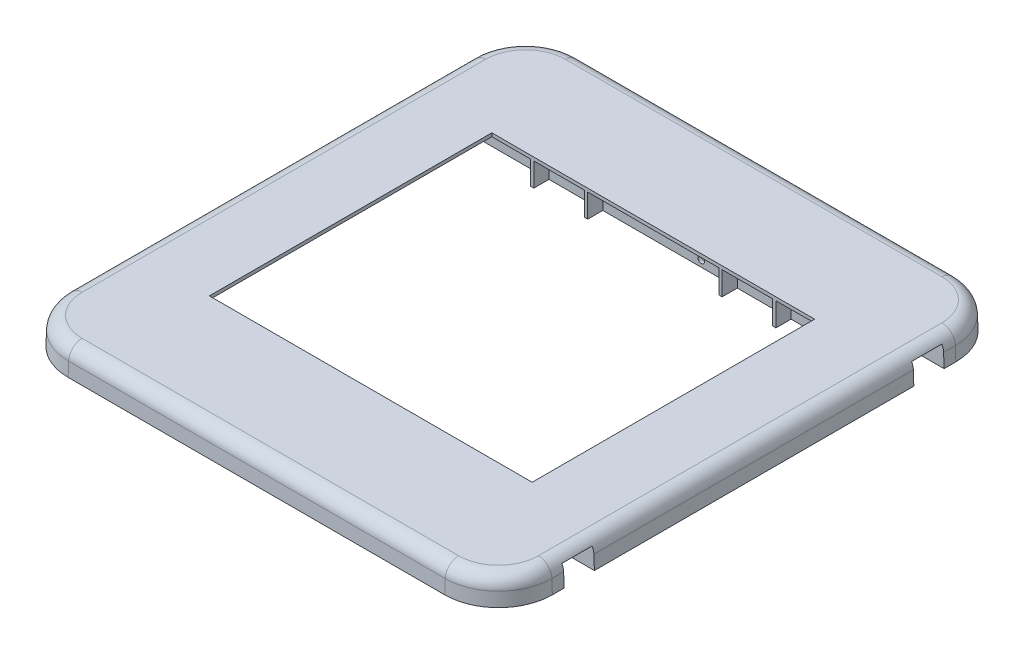
from build123d import *

# Parameters (mm, degrees)
EXTRUDE1_DEPTH     = 25.4
DRAFT1_ANGLE       = -2
FILLET1_R          = 12.7
SHELL2_T           = -3.175
RIB1_REACH         = 335.36
SKETCH3_WALLS_W    = 1109.591591228
SKETCH3_WALLS_H    = 3.175
SKETCH3_WALLS_W_2  = 1112.768526531
SKETCH4_W          = 28.575
SKETCH4_H          = 19.05
CUT_EXTRUDE2_DEPTH = 334.359880758
CUT_EXTRUDE3_REACH = 360.76
CUT_EXTRUDE3_START = -25.4
SKETCH6_R          = 3.175
RIB4_REACH         = 334.936
SKETCH9_WALLS_W    = 3.175
SKETCH9_WALLS_H    = 696.447518122
RIB4_DRAFT_ANGLE   = 2
RIB5_REACH         = 335.36
SKETCH11_WALLS_W   = 3.175
SKETCH11_WALLS_H   = 963.994761516
SKETCH11_WALLS_H_2 = 967.169761516
SKETCH10_W         = 304.8
SKETCH10_H         = 266.7
CUT_EXTRUDE4_DEPTH = 334.359880758


with BuildPart() as part:
    # Sketch1 → Extrude1 (new body)
    with BuildSketch(Plane(origin=(0, 0, 0), x_dir=(1, 0, 0), z_dir=(0, 1, 0))):
        with BuildLine():
            Line((228.6, 0), (228.6, 190.5))
            ThreePointArc((228.6, 190.5), (213.721024484, 226.421024484), (177.8, 241.3))
            Line((177.8, 241.3), (-177.8, 241.3))
            ThreePointArc((-177.8, 241.3), (-213.721024484, 226.421024484), (-228.6, 190.5))
            Line((-228.6, 190.5), (-228.6, 0))
            Line((-228.6, 0), (228.6, 0))
        make_face()
    extrude(amount=EXTRUDE1_DEPTH)

    # Draft1
    draft1_faces = [part.faces().sort_by_distance(p)[0] for p in [
        (228.6, 12.7, -95.25),
    ]]
    draft(draft1_faces, Plane(origin=(-177.8, 0, -190.5), x_dir=(0, 0, -1), z_dir=(0, -1, 0)), DRAFT1_ANGLE)

    # Fillet1
    fillet1_edges = [part.edges().sort_by_distance(p)[0] for p in [
        (227.713012455, 25.4, -95.25),
        (213.093829576, 25.4, -225.793829576),
        (0, 25.4, -240.413012455),
        (-213.093829576, 25.4, -225.793829576),
        (-227.713012455, 25.4, -95.25),
    ]]
    fillet(fillet1_edges, radius=FILLET1_R)

    # Shell2
    shell2_openings = [part.faces().sort_by_distance(p)[0] for p in [
        (0, 12.636517927, 0),
        (0, 0, -119.541485653),
    ]]
    offset(amount=SHELL2_T, openings=shell2_openings, kind=Kind.INTERSECTION)

    # Sketch3 walls → Rib1 (add, up to next)
    with BuildSketch(Plane.XZ, mode=Mode.PRIVATE) as rib1_sk1:
        with Locations((-4.987149841, -149.225)):
            Rectangle(SKETCH3_WALLS_W, SKETCH3_WALLS_H)
    rib1_tool1 = extrude(rib1_sk1.sketch, amount=-RIB1_REACH, mode=Mode.PRIVATE) - part.part
    # Sketch3 walls → Rib1 (add, up to next)
    with BuildSketch(Plane.XZ, mode=Mode.PRIVATE) as rib1_sk2:
        with Locations((-6.575617492, -180.975)):
            Rectangle(SKETCH3_WALLS_W_2, SKETCH3_WALLS_H)
    rib1_tool2 = extrude(rib1_sk2.sketch, amount=-RIB1_REACH, mode=Mode.PRIVATE) - part.part
    add(rib1_tool1.solids().sort_by_distance((-4.987149841, 0, -149.225))[0])
    add(rib1_tool2.solids().sort_by_distance((-6.575617493, 0, -180.975))[0])

    # Sketch4 → Cut-Extrude2 (cut, through all)
    with BuildSketch(Plane(origin=(0, 0, 0), x_dir=(0, 0, -1), z_dir=(1, 0, 0))):
        with Locations((165.1, 9.525)):
            Rectangle(SKETCH4_W, SKETCH4_H)
    extrude(amount=CUT_EXTRUDE2_DEPTH, mode=Mode.SUBTRACT)

    # Sketch6 → Cut-Extrude3 (cut, up to next)
    with BuildSketch(Plane.XY.offset(CUT_EXTRUDE3_START), mode=Mode.PRIVATE) as cut_extrude3_sk1:
        with Locations((208.935409058, 6.35)):
            Circle(SKETCH6_R)
    cut_extrude3_tool1 = extrude(cut_extrude3_sk1.sketch, amount=-CUT_EXTRUDE3_REACH, mode=Mode.PRIVATE) & part.part
    # Sketch6 → Cut-Extrude3 (cut, up to next)
    with BuildSketch(Plane.XY.offset(CUT_EXTRUDE3_START), mode=Mode.PRIVATE) as cut_extrude3_sk2:
        with Locations((31.135409058, 6.35)):
            Circle(SKETCH6_R)
    cut_extrude3_tool2 = extrude(cut_extrude3_sk2.sketch, amount=-CUT_EXTRUDE3_REACH, mode=Mode.PRIVATE) & part.part
    add(cut_extrude3_tool1.solids().sort_by_distance((208.935409, 6.35, -25.4))[0], mode=Mode.SUBTRACT)
    add(cut_extrude3_tool1.solids().sort_by_distance((208.935409, 6.35, -25.4))[1], mode=Mode.SUBTRACT)
    add(cut_extrude3_tool2.solids().sort_by_distance((31.135409, 6.35, -25.4))[0], mode=Mode.SUBTRACT)
    add(cut_extrude3_tool2.solids().sort_by_distance((31.135409, 6.35, -25.4))[1], mode=Mode.SUBTRACT)

    # Sketch9 walls → Rib4 (add, up to next)
    with BuildSketch(Plane.XZ.offset(-19.05), mode=Mode.PRIVATE) as rib4_sk1:
        with Locations((63.5, -165.1)):
            Rectangle(SKETCH9_WALLS_W, SKETCH9_WALLS_H)
    rib4_tool1 = extrude(rib4_sk1.sketch, amount=-RIB4_REACH, mode=Mode.PRIVATE) - part.part
    # Sketch9 walls → Rib4 (add, up to next)
    with BuildSketch(Plane.XZ.offset(-19.05), mode=Mode.PRIVATE) as rib4_sk2:
        with Locations((-63.5, -165.1)):
            Rectangle(SKETCH9_WALLS_W, SKETCH9_WALLS_H)
    rib4_tool2 = extrude(rib4_sk2.sketch, amount=-RIB4_REACH, mode=Mode.PRIVATE) - part.part
    add(rib4_tool1.solids().sort_by_distance((63.5, 19.05, -165.1))[0])
    add(rib4_tool2.solids().sort_by_distance((-63.5, 19.05, -165.1))[0])

    # Rib4 draft
    rib4_draft_faces = [part.faces().sort_by_distance(p)[0] for p in [
        (61.9125, 19.55, -165.1),
        (65.0875, 19.55, -165.1),
        (-65.0875, 19.55, -165.1),
        (-61.9125, 19.55, -165.1),
    ]]
    draft(rib4_draft_faces, Plane(origin=(63.5, 19.05, -165.1), x_dir=(1, 0, 0), z_dir=(0, -1, 0)), RIB4_DRAFT_ANGLE)

    # Mirror1: part across plane


with BuildPart() as part_1:
    add(part.part)
    add(part.part.mirror(Plane(origin=(-228.6, 25.4, 0), x_dir=(1, 0, 0), z_dir=(0, 0, -1))))

    # Sketch11 walls → Rib5 (add, up to next)
    with BuildSketch(Plane.XZ, mode=Mode.PRIVATE) as rib5_sk1:
        with Locations((63.5, 0)):
            Rectangle(SKETCH11_WALLS_W, SKETCH11_WALLS_H)
    rib5_tool1 = extrude(rib5_sk1.sketch, amount=-RIB5_REACH, mode=Mode.PRIVATE) - part_1.part
    # Sketch11 walls → Rib5 (add, up to next)
    with BuildSketch(Plane.XZ, mode=Mode.PRIVATE) as rib5_sk2:
        with Locations((-63.5, -1.5875)):
            Rectangle(SKETCH11_WALLS_W, SKETCH11_WALLS_H_2)
    rib5_tool2 = extrude(rib5_sk2.sketch, amount=-RIB5_REACH, mode=Mode.PRIVATE) - part_1.part
    # Sketch11 walls → Rib5 (add, up to next)
    with BuildSketch(Plane.XZ, mode=Mode.PRIVATE) as rib5_sk3:
        with Locations((114.3, 0)):
            Rectangle(SKETCH11_WALLS_W, SKETCH11_WALLS_H)
    rib5_tool3 = extrude(rib5_sk3.sketch, amount=-RIB5_REACH, mode=Mode.PRIVATE) - part_1.part
    # Sketch11 walls → Rib5 (add, up to next)
    with BuildSketch(Plane.XZ, mode=Mode.PRIVATE) as rib5_sk4:
        with Locations((-114.3, -1.5875)):
            Rectangle(SKETCH11_WALLS_W, SKETCH11_WALLS_H_2)
    rib5_tool4 = extrude(rib5_sk4.sketch, amount=-RIB5_REACH, mode=Mode.PRIVATE) - part_1.part
    add(rib5_tool1.solids().sort_by_distance((63.5, 0, 0))[0])
    add(rib5_tool2.solids().sort_by_distance((-63.5, 0, -1.5875))[0])
    add(rib5_tool3.solids().sort_by_distance((114.3, 0, 0))[0])
    add(rib5_tool4.solids().sort_by_distance((-114.3, 0, -1.5875))[0])

    # Sketch10 → Cut-Extrude4 (cut, through all)
    with BuildSketch(Plane(origin=(0, 25.4, 0), x_dir=(-1, 0, 0), z_dir=(0, 1, 0))):
        Rectangle(SKETCH10_W, SKETCH10_H)
    extrude(amount=-CUT_EXTRUDE4_DEPTH, mode=Mode.SUBTRACT)


solid = part_1.part
